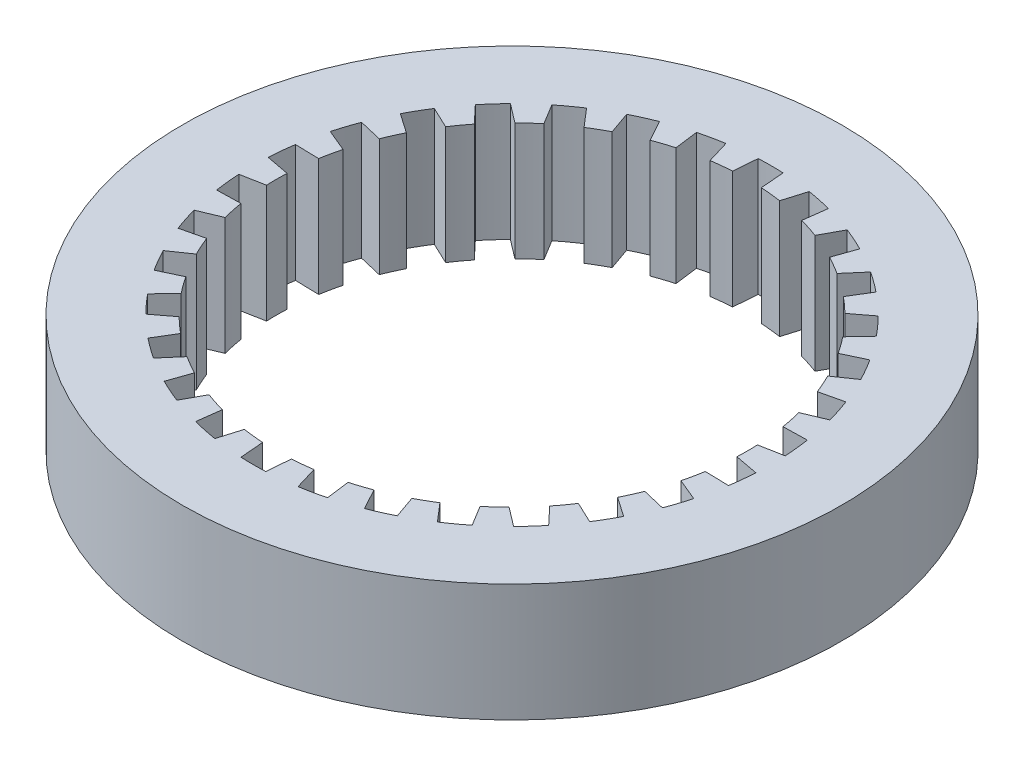
from build123d import *

# Parameters (mm, degrees)
SKETCH1_R           = 17.78
BOSS_EXTRUDE1_DEPTH = 6.35
CUT_EXTRUDE1_DEPTH  = 7.35


with BuildPart() as part:
    # Sketch1 → Boss-Extrude1 (new body)
    with BuildSketch(Plane(origin=(0, 0, 0), x_dir=(1, 0, 0), z_dir=(0, 1, 0))):
        Circle(SKETCH1_R)
    extrude(amount=BOSS_EXTRUDE1_DEPTH)

    # Sketch2 → Cut-Extrude1 (cut, through all)
    with BuildSketch(Plane(origin=(0, 6.35, 0), x_dir=(1, 0, 0), z_dir=(0, 1, 0))):
        with BuildLine():
            Line((-0.670254455, 13.953911959), (-0.775316452, 12.67631194))
            ThreePointArc((-0.775316452, 12.67631194), (-1.327511483, 12.630428071), (-1.877179521, 12.560501465))
            Line((-1.877179521, 12.560501465), (-2.245573641, 13.788339241))
            ThreePointArc((-2.245573641, 13.788339241), (-2.904526321, 13.664721982), (-3.556789216, 13.509631767))
            Line((-3.556789216, 13.509631767), (-3.393927376, 12.238106756))
            ThreePointArc((-3.393927376, 12.238106756), (-3.924515829, 12.078417757), (-4.447633742, 11.895736803))
            Line((-4.447633742, 11.895736803), (-5.063259395, 13.020149934))
            ThreePointArc((-5.063259395, 13.020149934), (-5.682110904, 12.762230043), (-6.287875221, 12.474915839))
            Line((-6.287875221, 12.474915839), (-5.864207388, 11.265037581))
            ThreePointArc((-5.864207388, 11.265037581), (-6.35, 10.998522628), (-6.823705026, 10.711071362))
            Line((-6.823705026, 10.711071362), (-7.659656416, 11.682917597))
            ThreePointArc((-7.659656416, 11.682917597), (-8.211359975, 11.301967411), (-8.744150906, 10.894986229))
            Line((-8.744150906, 10.894986229), (-8.078193398, 9.799632209))
            ThreePointArc((-8.078193398, 9.799632209), (-8.497958701, 9.437939284), (-8.901547657, 9.058280704))
            Line((-8.901547657, 9.058280704), (-9.921289697, 9.835085701))
            ThreePointArc((-9.921289697, 9.835085701), (-10.381733212, 9.347754571), (-10.818265238, 8.83889344))
            Line((-10.818265238, 8.83889344), (-9.939123592, 7.905935885))
            ThreePointArc((-9.939123592, 7.905935885), (-10.274515829, 7.464872704), (-10.59034994, 7.009599713))
            Line((-10.59034994, 7.009599713), (-11.749315011, 7.557413365))
            ThreePointArc((-11.749315011, 7.557413365), (-12.098374891, 6.985), (-12.419569467, 6.396498594))
            Line((-12.419569467, 6.396498594), (-11.365666392, 5.666712226))
            ThreePointArc((-11.365666392, 5.666712226), (-11.602027312, 5.165555367), (-11.816303113, 4.654565579))
            Line((-11.816303113, 4.654565579), (-13.063838879, 4.949445801))
            ThreePointArc((-13.063838879, 4.949445801), (-13.286259533, 4.316967411), (-13.478078914, 3.674546066))
            Line((-13.478078914, 3.674546066), (-12.295475033, 3.179826051))
            ThreePointArc((-12.295475033, 3.179826051), (-12.422474529, 2.640478473), (-12.52582714, 2.096104594))
            Line((-12.52582714, 2.096104594), (-13.807410301, 2.125163705))
            ThreePointArc((-13.807410301, 2.125163705), (-13.893470878, 1.460262632), (-13.947531638, 0.791998242))
            Line((-13.947531638, 0.791998242), (-12.687912414, 0.55396622))
            ThreePointArc((-12.687912414, 0.55396622), (-12.7, 0), (-12.687912414, -0.55396622))
            Line((-12.687912414, -0.55396622), (-13.947531638, -0.791998242))
            ThreePointArc((-13.947531638, -0.791998242), (-13.893470878, -1.460262632), (-13.807410301, -2.125163705))
            Line((-13.807410301, -2.125163705), (-12.52582714, -2.096104594))
            ThreePointArc((-12.52582714, -2.096104594), (-12.422474529, -2.640478473), (-12.295475033, -3.179826051))
            Line((-12.295475033, -3.179826051), (-13.478078914, -3.674546066))
            ThreePointArc((-13.478078914, -3.674546066), (-13.286259533, -4.316967411), (-13.063838879, -4.949445801))
            Line((-13.063838879, -4.949445801), (-11.816303113, -4.654565579))
            ThreePointArc((-11.816303113, -4.654565579), (-11.602027312, -5.165555367), (-11.365666392, -5.666712226))
            Line((-11.365666392, -5.666712226), (-12.419569467, -6.396498594))
            ThreePointArc((-12.419569467, -6.396498594), (-12.098374891, -6.985), (-11.749315011, -7.557413365))
            Line((-11.749315011, -7.557413365), (-10.59034994, -7.009599713))
            ThreePointArc((-10.59034994, -7.009599713), (-10.274515829, -7.464872704), (-9.939123592, -7.905935885))
            Line((-9.939123592, -7.905935885), (-10.818265238, -8.83889344))
            ThreePointArc((-10.818265238, -8.83889344), (-10.381733212, -9.347754571), (-9.921289697, -9.835085701))
            Line((-9.921289697, -9.835085701), (-8.901547657, -9.058280704))
            ThreePointArc((-8.901547657, -9.058280704), (-8.497958701, -9.437939284), (-8.078193398, -9.799632209))
            Line((-8.078193398, -9.799632209), (-8.744150906, -10.894986229))
            ThreePointArc((-8.744150906, -10.894986229), (-8.211359975, -11.301967411), (-7.659656416, -11.682917597))
            Line((-7.659656416, -11.682917597), (-6.823705026, -10.711071362))
            ThreePointArc((-6.823705026, -10.711071362), (-6.35, -10.998522628), (-5.864207388, -11.265037581))
            Line((-5.864207388, -11.265037581), (-6.287875221, -12.474915839))
            ThreePointArc((-6.287875221, -12.474915839), (-5.682110904, -12.762230043), (-5.063259395, -13.020149934))
            Line((-5.063259395, -13.020149934), (-4.447633742, -11.895736803))
            ThreePointArc((-4.447633742, -11.895736803), (-3.924515829, -12.078417757), (-3.393927376, -12.238106756))
            Line((-3.393927376, -12.238106756), (-3.556789216, -13.509631767))
            ThreePointArc((-3.556789216, -13.509631767), (-2.904526321, -13.664721982), (-2.245573641, -13.788339241))
            Line((-2.245573641, -13.788339241), (-1.877179521, -12.560501465))
            ThreePointArc((-1.877179521, -12.560501465), (-1.327511483, -12.630428071), (-0.775316452, -12.67631194))
            Line((-0.775316452, -12.67631194), (-0.670254455, -13.953911959))
            ThreePointArc((-0.670254455, -13.953911959), (0, -13.97), (0.670254455, -13.953911959))
            Line((0.670254455, -13.953911959), (0.775316452, -12.67631194))
            ThreePointArc((0.775316452, -12.67631194), (1.327511483, -12.630428071), (1.877179521, -12.560501465))
            Line((1.877179521, -12.560501465), (2.245573641, -13.788339241))
            ThreePointArc((2.245573641, -13.788339241), (2.904526321, -13.664721982), (3.556789216, -13.509631767))
            Line((3.556789216, -13.509631767), (3.393927376, -12.238106756))
            ThreePointArc((3.393927376, -12.238106756), (3.924515829, -12.078417757), (4.447633742, -11.895736803))
            Line((4.447633742, -11.895736803), (5.063259395, -13.020149934))
            ThreePointArc((5.063259395, -13.020149934), (5.682110904, -12.762230043), (6.287875221, -12.474915839))
            Line((6.287875221, -12.474915839), (5.864207388, -11.265037581))
            ThreePointArc((5.864207388, -11.265037581), (6.35, -10.998522628), (6.823705026, -10.711071362))
            Line((6.823705026, -10.711071362), (7.659656416, -11.682917597))
            ThreePointArc((7.659656416, -11.682917597), (8.211359975, -11.301967411), (8.744150906, -10.894986229))
            Line((8.744150906, -10.894986229), (8.078193398, -9.799632209))
            ThreePointArc((8.078193398, -9.799632209), (8.497958701, -9.437939284), (8.901547657, -9.058280704))
            Line((8.901547657, -9.058280704), (9.921289697, -9.835085701))
            ThreePointArc((9.921289697, -9.835085701), (10.381733212, -9.347754571), (10.818265238, -8.83889344))
            Line((10.818265238, -8.83889344), (9.939123592, -7.905935885))
            ThreePointArc((9.939123592, -7.905935885), (10.274515829, -7.464872704), (10.59034994, -7.009599713))
            Line((10.59034994, -7.009599713), (11.749315011, -7.557413365))
            ThreePointArc((11.749315011, -7.557413365), (12.098374891, -6.985), (12.419569467, -6.396498594))
            Line((12.419569467, -6.396498594), (11.365666392, -5.666712226))
            ThreePointArc((11.365666392, -5.666712226), (11.602027312, -5.165555367), (11.816303113, -4.654565579))
            Line((11.816303113, -4.654565579), (13.063838879, -4.949445801))
            ThreePointArc((13.063838879, -4.949445801), (13.286259533, -4.316967411), (13.478078914, -3.674546066))
            Line((13.478078914, -3.674546066), (12.295475033, -3.179826051))
            ThreePointArc((12.295475033, -3.179826051), (12.422474529, -2.640478473), (12.52582714, -2.096104594))
            Line((12.52582714, -2.096104594), (13.807410301, -2.125163705))
            ThreePointArc((13.807410301, -2.125163705), (13.893470878, -1.460262632), (13.947531638, -0.791998242))
            Line((13.947531638, -0.791998242), (12.687912414, -0.55396622))
            ThreePointArc((12.687912414, -0.55396622), (12.7, 0), (12.687912414, 0.55396622))
            Line((12.687912414, 0.55396622), (13.947531638, 0.791998242))
            ThreePointArc((13.947531638, 0.791998242), (13.893470878, 1.460262632), (13.807410301, 2.125163705))
            Line((13.807410301, 2.125163705), (12.52582714, 2.096104594))
            ThreePointArc((12.52582714, 2.096104594), (12.422474529, 2.640478473), (12.295475033, 3.179826051))
            Line((12.295475033, 3.179826051), (13.478078914, 3.674546066))
            ThreePointArc((13.478078914, 3.674546066), (13.286259533, 4.316967411), (13.063838879, 4.949445801))
            Line((13.063838879, 4.949445801), (11.816303113, 4.654565579))
            ThreePointArc((11.816303113, 4.654565579), (11.602027312, 5.165555367), (11.365666392, 5.666712226))
            Line((11.365666392, 5.666712226), (12.419569467, 6.396498594))
            ThreePointArc((12.419569467, 6.396498594), (12.098374891, 6.985), (11.749315011, 7.557413365))
            Line((11.749315011, 7.557413365), (10.59034994, 7.009599713))
            ThreePointArc((10.59034994, 7.009599713), (10.274515829, 7.464872704), (9.939123592, 7.905935885))
            Line((9.939123592, 7.905935885), (10.818265238, 8.83889344))
            ThreePointArc((10.818265238, 8.83889344), (10.381733212, 9.347754571), (9.921289697, 9.835085701))
            Line((9.921289697, 9.835085701), (8.901547657, 9.058280704))
            ThreePointArc((8.901547657, 9.058280704), (8.497958701, 9.437939284), (8.078193398, 9.799632209))
            Line((8.078193398, 9.799632209), (8.744150906, 10.894986229))
            ThreePointArc((8.744150906, 10.894986229), (8.211359975, 11.301967411), (7.659656416, 11.682917597))
            Line((7.659656416, 11.682917597), (6.823705026, 10.711071362))
            ThreePointArc((6.823705026, 10.711071362), (6.35, 10.998522628), (5.864207388, 11.265037581))
            Line((5.864207388, 11.265037581), (6.287875221, 12.474915839))
            ThreePointArc((6.287875221, 12.474915839), (5.682110904, 12.762230043), (5.063259395, 13.020149934))
            Line((5.063259395, 13.020149934), (4.447633742, 11.895736803))
            ThreePointArc((4.447633742, 11.895736803), (3.924515829, 12.078417757), (3.393927376, 12.238106756))
            Line((3.393927376, 12.238106756), (3.556789216, 13.509631767))
            ThreePointArc((3.556789216, 13.509631767), (2.904526321, 13.664721982), (2.245573641, 13.788339241))
            Line((2.245573641, 13.788339241), (1.877179521, 12.560501465))
            ThreePointArc((1.877179521, 12.560501465), (1.327511483, 12.630428071), (0.775316452, 12.67631194))
            Line((0.775316452, 12.67631194), (0.670254455, 13.953911959))
            ThreePointArc((0.670254455, 13.953911959), (0, 13.97), (-0.670254455, 13.953911959))
        make_face()
    extrude(amount=-CUT_EXTRUDE1_DEPTH, mode=Mode.SUBTRACT)


solid = part.part
